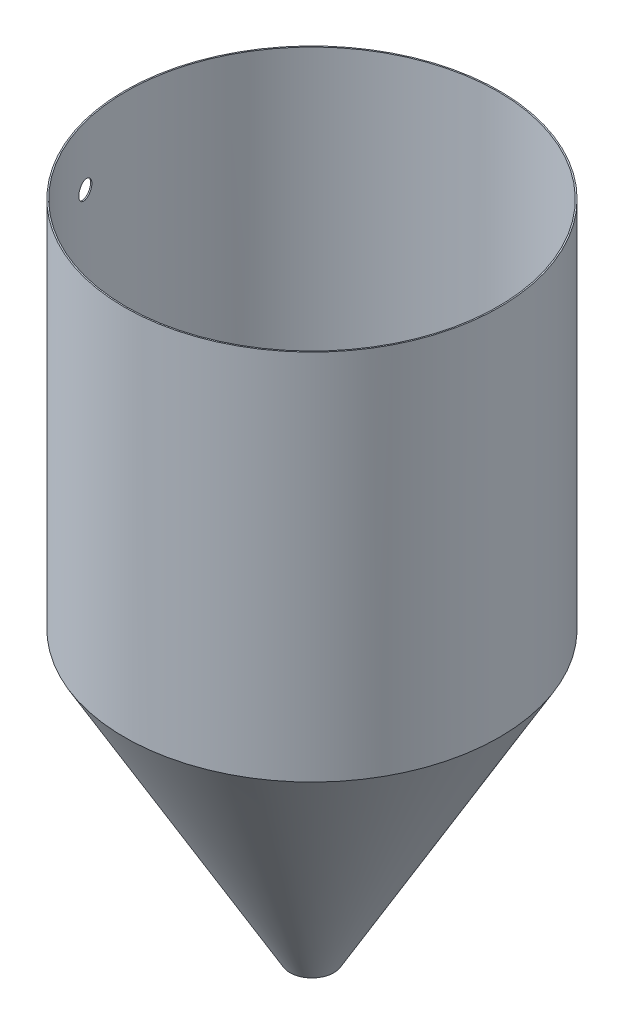
from build123d import *

# Parameters (mm, degrees)
SKETCH7_R           = 230.1875
SKETCH7_R_2         = 228.6
BOSS_EXTRUDE1_DEPTH = 457.2
SKETCH9_R           = 10.795
CUT_EXTRUDE1_DEPTH  = 304.8


with BuildPart() as part:
    # Sketch7 → Boss-Extrude1 (new body)
    with BuildSketch(Plane(origin=(0, 0, 0), x_dir=(1, 0, 0), z_dir=(0, 1, 0))):
        Circle(SKETCH7_R)
        Circle(SKETCH7_R_2, mode=Mode.SUBTRACT)
    extrude(amount=BOSS_EXTRUDE1_DEPTH)

    # Sketch8 → Revolve1 (revolve)
    with BuildSketch(Plane.XY):
        Polygon((228.6, 0), (230.1875, 0), (26.9875, -351.952724098), (25.4, -351.952724098), align=None)
    revolve(axis=Axis((0, 0, 0), (0, -1, 0)))

    # Sketch9 → Cut-Extrude1 (cut)
    with BuildSketch(Plane(origin=(0, 0, 0), x_dir=(0, 0, -1), z_dir=(1, 0, 0))):
        with Locations((-57.15, 384.980800527)):
            Circle(SKETCH9_R)
    extrude(amount=-CUT_EXTRUDE1_DEPTH, mode=Mode.SUBTRACT)


solid = part.part
